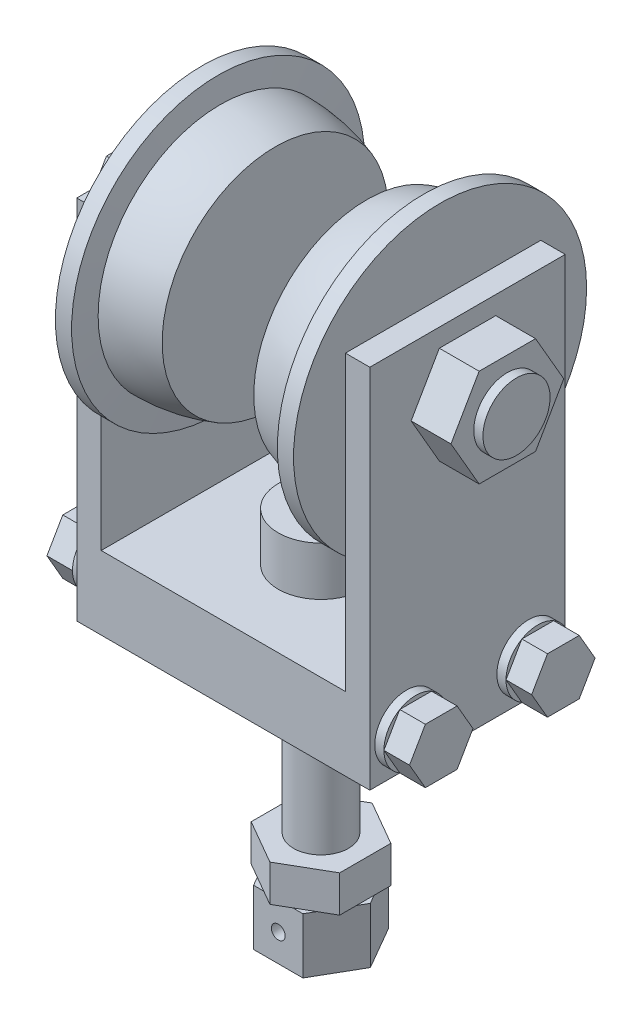
from build123d import *

# Parameters (mm, degrees)
YOKE_CROSS_SECTION_W           = 101.6
YOKE_CROSS_SECTION_H           = 38.1
YOKE_DEPTH                     = 63.5
SIDEPLATE_PROFILE_W            = 101.6
SIDEPLATE_PROFILE_H            = 190.5
SIDEPLATE_DEPTH                = 12.7
WHEEL_PIN_NUT_DEPTH            = 20.701
WHEEL_PIN_PROJECTION_PROFILE_R = 17.4625
WHEEL_PIN_PROJECTION_DEPTH     = 4.7625
LOCKNUTS_PROFILE_R             = 16.4973
LOCKNUTS_DEPTH                 = 4.7625
SCREWS_DEPTH                   = 13.3096
PROFILE_R                      = 22.225
KING_BOLT_HEAD_DEPTH           = 25.4
DIA_R                          = 14.2875
KING_BOLT_DEPTH                = 82.55
KING_BOLT_JAM_NUT_DEPTH        = 19.05
KING_BOLT_NUT_DEPTH            = 28.9306
SKETCH5_R                      = 14.2875
EXTENDED_KING_BOLT_DEPTH       = 6.35
CHAMFER1_SIZE                  = 2.38125
COTTER_PIN_HOLE_REACH          = 100.425
SKETCH7_R                      = 3.571875
SKETCH8_R                      = 30.1625
SKETCH8_R_2                    = 25.4
SPACER_DEPTH                   = 12.7


with BuildPart() as part:
    # YOKE CROSS SECTION → YOKE (new body)
    with BuildSketch(Plane(origin=(0, 0, 0), x_dir=(0, 0, -1), z_dir=(1, 0, 0))):
        with Locations((0, 19.05)):
            Rectangle(YOKE_CROSS_SECTION_W, YOKE_CROSS_SECTION_H)
    extrude(amount=YOKE_DEPTH)

    # SIDEPLATE PROFILE → SIDEPLATE (add)
    with BuildSketch(Plane(origin=(63.5, 0, 0), x_dir=(0, 0, -1), z_dir=(1, 0, 0))):
        with Locations((0, 95.25)):
            Rectangle(SIDEPLATE_PROFILE_W, SIDEPLATE_PROFILE_H)
    extrude(amount=SIDEPLATE_DEPTH)

    # WHEEL PIN NUT PROFILE → WHEEL PIN NUT (add)
    with BuildSketch(Plane(origin=(76.2, 0, 0), x_dir=(0, 0, -1), z_dir=(1, 0, 0))):
        Polygon((29.329393675, 155.575), (14.664696837, 180.975), (-14.664696837, 180.975), (-29.329393675, 155.575), (-14.664696837, 130.175), (14.664696837, 130.175), align=None)
    extrude(amount=WHEEL_PIN_NUT_DEPTH)

    # WHEEL PIN PROJECTION PROFILE → WHEEL PIN PROJECTION (add)
    with BuildSketch(Plane(origin=(96.901, 0, 0), x_dir=(0, 0, -1), z_dir=(1, 0, 0))):
        with Locations((0, 155.575)):
            Circle(WHEEL_PIN_PROJECTION_PROFILE_R)
    extrude(amount=WHEEL_PIN_PROJECTION_DEPTH)

    # LOCKNUTS PROFILE → LOCKNUTS (add)
    with BuildSketch(Plane(origin=(76.2, 0, 0), x_dir=(0, 0, -1), z_dir=(1, 0, 0))):
        with Locations((-31.75, 19.05)):
            Circle(LOCKNUTS_PROFILE_R)
    locknuts = extrude(amount=LOCKNUTS_DEPTH)

    # SCREWS PROFILE → SCREWS (add)
    with BuildSketch(Plane(origin=(80.9625, 0, 0), x_dir=(0, 0, -1), z_dir=(1, 0, 0))):
        Polygon((-15.252216058, 19.05), (-23.501108029, 33.3375), (-39.998891971, 33.3375), (-48.247783942, 19.05), (-39.998891971, 4.7625), (-23.501108029, 4.7625), align=None)
    screws = extrude(amount=SCREWS_DEPTH)

    # PROFILE → KING BOLT HEAD (add)
    with BuildSketch(Plane(origin=(0, 38.1, 0), x_dir=(-1, 0, 0), z_dir=(0, 1, 0))):
        with Locations(Location((0, 0, 0), (0, 0, 90))):  # turned: the seam where the file's is
            Circle(PROFILE_R)
    extrude(amount=KING_BOLT_HEAD_DEPTH)

    # Mirror1: LOCKNUTS, SCREWS across plane
    add(locknuts.mirror(Plane.XY))
    add(screws.mirror(Plane.XY))

    # Mirror5: part across plane


with BuildPart() as part_1:
    add(part.part)
    add(part.part.mirror(Plane(origin=(0, 0, 0), x_dir=(0, 0, 1), z_dir=(1, 0, 0))))

    # DIA. → KING BOLT (add)
    with BuildSketch(Plane.XZ):
        with Locations(Location((0, 0, 0), (0, 0, 90))):  # turned: the seam where the file's is
            Circle(DIA_R)
    extrude(amount=KING_BOLT_DEPTH)

    # KING BOLT JAN NUT PROFILE → KING BOLT JAM NUT (add)
    with BuildSketch(Plane.XZ.offset(82.55)):
        Polygon((0, -26.579763018), (23.01875, -13.289881509), (23.01875, 13.289881509), (0, 26.579763018), (-23.01875, 13.289881509), (-23.01875, -13.289881509), align=None)
    extrude(amount=KING_BOLT_JAM_NUT_DEPTH)

    # KING BOLT NUT PROFILE → KING BOLT NUT (add)
    with BuildSketch(Plane.XZ.offset(101.6)):
        Polygon((25.663219465, 0), (12.831609733, 22.225), (-12.831609733, 22.225), (-25.663219465, 0), (-12.831609733, -22.225), (12.831609733, -22.225), align=None)
    extrude(amount=KING_BOLT_NUT_DEPTH)

    # Sketch5 → EXTENDED KING BOLT (add)
    with BuildSketch(Plane.XZ.offset(130.5306)):
        with Locations(Location((0, 0, 0), (0, 0, 90))):  # turned: the seam where the file's is
            Circle(SKETCH5_R)
    extrude(amount=EXTENDED_KING_BOLT_DEPTH)

    # Chamfer1
    chamfer1_edges = [part_1.edges().sort_by_distance(p)[0] for p in [
        (0, -136.8806, -14.2875),
    ]]
    chamfer(chamfer1_edges, length=CHAMFER1_SIZE)

    # Sketch6 → WHEEL (revolve)
    with BuildSketch(Plane.XY, mode=Mode.PRIVATE) as wheel_sk:
        with BuildLine():
            Line((61.9125, 180.975), (61.9125, 231.775))
            Line((61.9125, 231.775), (53.498606027, 231.775))
            Line((53.498606027, 231.775), (52.3875, 219.075))
            ThreePointArc((52.3875, 219.075), (37.906596955, 217.887675521), (23.8125, 214.357417256))
            Line((23.8125, 214.357417256), (23.8125, 155.575))
            Line((23.8125, 155.575), (63.5, 155.575))
            Line((63.5, 155.575), (63.5, 180.975))
            Line((63.5, 180.975), (61.9125, 180.975))
        make_face()
    wheel = revolve(wheel_sk.sketch.rotate(Axis((101.6635, 155.575, 0), (-1, 0, 0)), 90), axis=Axis((101.6635, 155.575, 0), (-1, 0, 0)))  # turned: the seam where the file's is

    # Mirror6: WHEEL across plane
    add(wheel.mirror(Plane(origin=(0, 0, 0), x_dir=(0, 0, 1), z_dir=(1, 0, 0))))

    # Sketch7 → COTTER PIN HOLE (cut, up to next)
    with BuildSketch(Plane.XY.offset(22.225), mode=Mode.PRIVATE) as cotter_pin_hole_sk1:
        with Locations((0, -116.2431)):
            Circle(SKETCH7_R)
    cotter_pin_hole_tool1 = extrude(cotter_pin_hole_sk1.sketch, amount=-COTTER_PIN_HOLE_REACH, mode=Mode.PRIVATE) & part_1.part
    add(cotter_pin_hole_tool1.solids().sort_by_distance((0, -116.2431, 22.225))[0], mode=Mode.SUBTRACT)

    # Sketch8 → SPACER (add)
    with BuildSketch(Plane.XZ):
        with Locations(Location((0, 0, 0), (0, 0, 90))):  # turned: the seam where the file's is
            Circle(SKETCH8_R)
        with Locations(Location((0, 0, 0), (0, 0, 270))):  # turned: the seam where the file's is
            Circle(SKETCH8_R_2, mode=Mode.SUBTRACT)
    extrude(amount=SPACER_DEPTH)


solid = part_1.part
